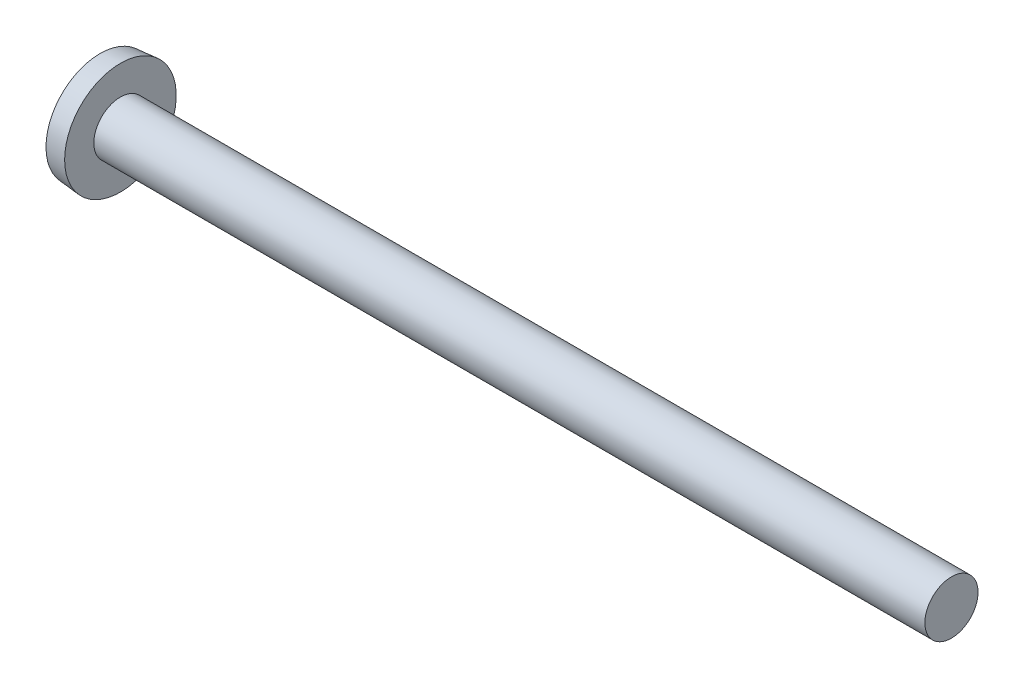
from build123d import *

# Parameters (mm, degrees)
SKETCH3_W         = 0.8636
SKETCH3_H         = 3.9116
SKETCH4_W         = 0.4318
SKETCH4_H         = 0.4318
CIRPATTERN1_COUNT = 2
CIRPATTERN1_ANGLE = 90


with BuildPart() as part:
    # BodySke → Base-Revolve (revolve)
    with BuildSketch(Plane.XY):
        with BuildLine():
            Line((1.7272, 1.4224), (1.7272, 2.9845))
            Line((1.7272, 2.9845), (0.635, 2.888944882))
            ThreePointArc((0.635, 2.888944882), (0.160622478, 1.478954659), (0, 0))
            Line((0, 0), (46.1772, 0))
            Line((46.1772, 0), (46.1772, 1.4224))
            Line((46.1772, 1.4224), (1.7272, 1.4224))
        make_face()
    revolve(axis=Axis((-25.4, 0, 0), (1, 0, 0)))

    # Sketch3 → Cross section 0
    with BuildSketch(Plane(origin=(0, 0, 0), x_dir=(0, 0, -1), z_dir=(1, 0, 0))):
        Rectangle(SKETCH3_W, SKETCH3_H)
    # Sketch4 → Cross section 1
    with BuildSketch(Plane(origin=(2.1844, 0, 0), x_dir=(0, 0, -1), z_dir=(1, 0, 0))):
        Rectangle(SKETCH4_W, SKETCH4_H)
    cross = loft(mode=Mode.SUBTRACT)

    # CirPattern1: Cross ×2 about axis
    cirpattern1_axis = Axis((0, 0, 0), (1, 0, 0))
    for i in range(1, CIRPATTERN1_COUNT):
        add(cross.rotate(cirpattern1_axis, i * CIRPATTERN1_ANGLE / (CIRPATTERN1_COUNT - 1)), mode=Mode.SUBTRACT)


solid = part.part
